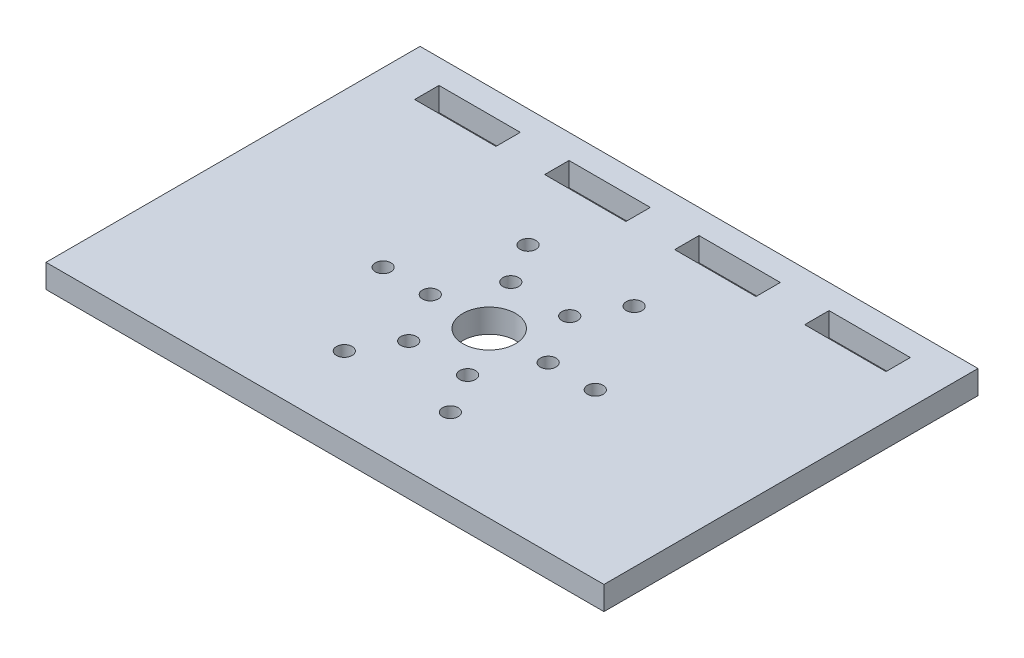
from build123d import *

# Parameters (mm, degrees)
SKETCH2_W           = 71
SKETCH2_H           = 47.6
SKETCH2_R           = 3.35
SKETCH2_R_2         = 1
SKETCH2_W_2         = 10.344
SKETCH2_H_2         = 3.1
BOSS_EXTRUDE1_DEPTH = 3


with BuildPart() as part:
    # Sketch2 → Boss-Extrude1 (new body)
    with BuildSketch(Plane(origin=(0, 0, 0), x_dir=(1, 0, 0), z_dir=(0, 1, 0))):
        with Locations((35.5, 23.8)):
            Rectangle(SKETCH2_W, SKETCH2_H)
        with Locations((35.5, 20.9)):
            Circle(SKETCH2_R, mode=Mode.SUBTRACT)
        with Locations((43, 20.9)):
            Circle(SKETCH2_R_2, mode=Mode.SUBTRACT)
        with Locations((49, 20.9)):
            Circle(SKETCH2_R_2, mode=Mode.SUBTRACT)
        with Locations((39.25, 14.404809472)):
            Circle(SKETCH2_R_2, mode=Mode.SUBTRACT)
        with Locations((42.25, 9.208657049)):
            Circle(SKETCH2_R_2, mode=Mode.SUBTRACT)
        with Locations((31.75, 14.404809472)):
            Circle(SKETCH2_R_2, mode=Mode.SUBTRACT)
        with Locations((28.75, 9.208657049)):
            Circle(SKETCH2_R_2, mode=Mode.SUBTRACT)
        with Locations((28, 20.9)):
            Circle(SKETCH2_R_2, mode=Mode.SUBTRACT)
        with Locations((22, 20.9)):
            Circle(SKETCH2_R_2, mode=Mode.SUBTRACT)
        with Locations((31.75, 27.395190528)):
            Circle(SKETCH2_R_2, mode=Mode.SUBTRACT)
        with Locations((28.75, 32.591342951)):
            Circle(SKETCH2_R_2, mode=Mode.SUBTRACT)
        with Locations((39.25, 27.395190528)):
            Circle(SKETCH2_R_2, mode=Mode.SUBTRACT)
        with Locations((42.25, 32.591342951)):
            Circle(SKETCH2_R_2, mode=Mode.SUBTRACT)
        with Locations((10.684, 42.95)):
            Rectangle(SKETCH2_W_2, SKETCH2_H_2, mode=Mode.SUBTRACT)
        with Locations((27.228, 42.95)):
            Rectangle(SKETCH2_W_2, SKETCH2_H_2, mode=Mode.SUBTRACT)
        with Locations((43.772, 42.95)):
            Rectangle(SKETCH2_W_2, SKETCH2_H_2, mode=Mode.SUBTRACT)
        with Locations((60.316, 42.95)):
            Rectangle(SKETCH2_W_2, SKETCH2_H_2, mode=Mode.SUBTRACT)
    extrude(amount=BOSS_EXTRUDE1_DEPTH)


solid = part.part
